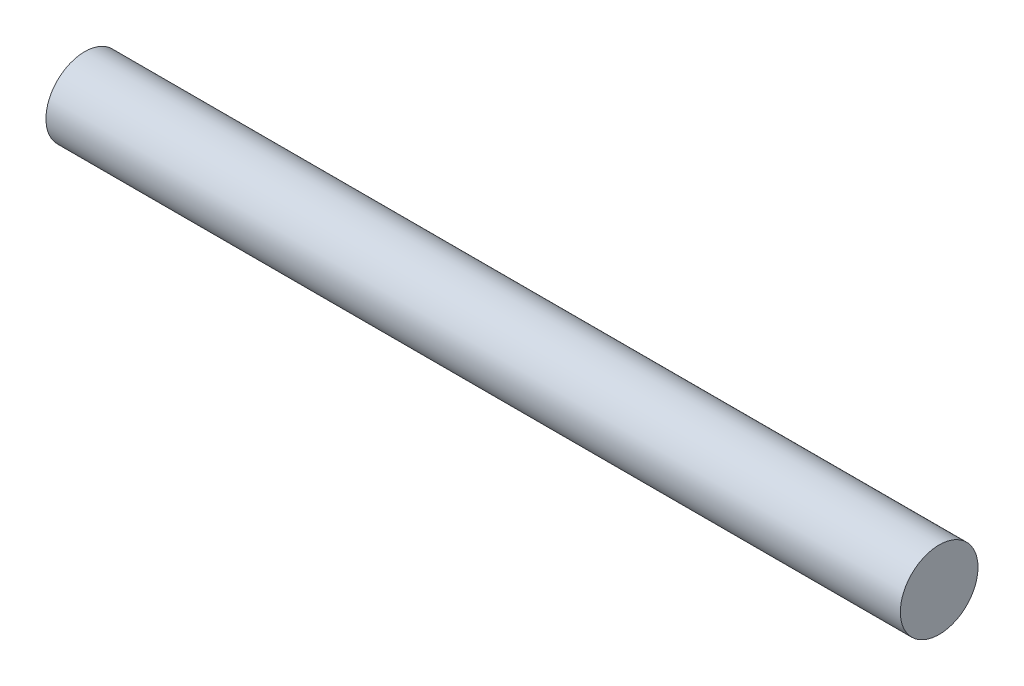
from build123d import *

# Parameters (mm, degrees)
SZKIC1_R                    = 2.5
DODANIE_WYCI_GNI_CIE1_DEPTH = 27.5


with BuildPart() as part:
    # Szkic1 → Dodanie-wyciągnięcie1 (new body, symmetric)
    with BuildSketch(Plane(origin=(0, 0, 0), x_dir=(0, 0, -1), z_dir=(1, 0, 0))):
        Circle(SZKIC1_R)
    extrude(amount=DODANIE_WYCI_GNI_CIE1_DEPTH, both=True)


solid = part.part
